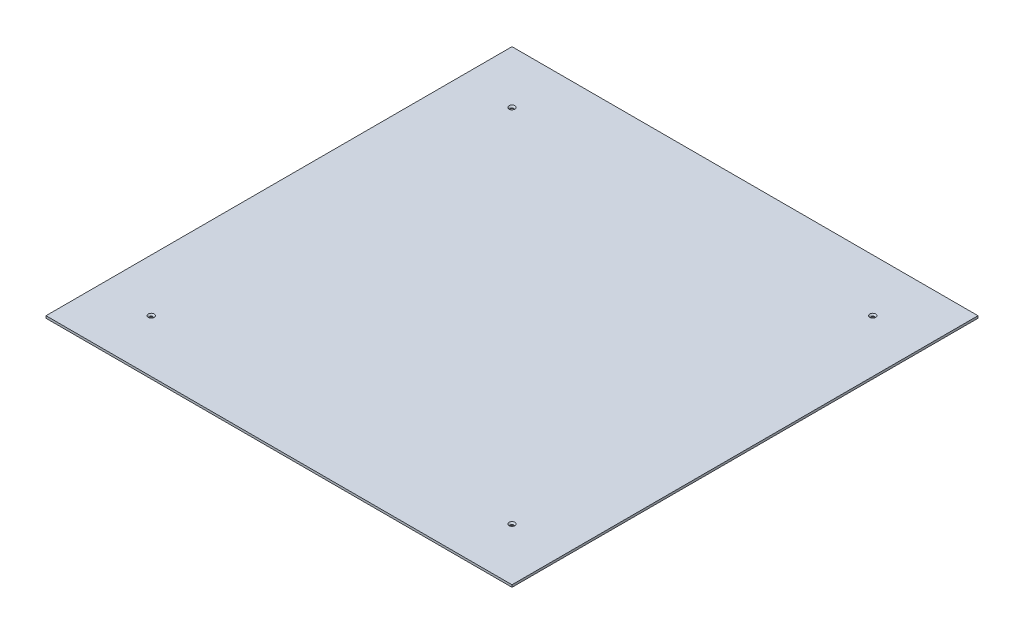
from build123d import *

# Parameters (mm, degrees)
SKETCH_1_W               = 310
SKETCH_1_H               = 310
EXTRUDE_1_DEPTH          = 1.5
HOLE_WIZARD_1_AT_2_COUNT = 2
HOLE_WIZARD_1_AT_2_PITCH = 240
HOLE_WIZARD_1_AT_3_COUNT = 2
HOLE_WIZARD_1_AT_3_PITCH = 339.41125497
HOLE_WIZARD_1_AT_4_COUNT = 2
HOLE_WIZARD_1_AT_4_PITCH = 240


with BuildPart() as part:
    # 草图1 → 凸台-拉伸1 (new body)
    with BuildSketch(Plane(origin=(0, 0, 0), x_dir=(1, 0, 0), z_dir=(0, 1, 0))):
        Rectangle(SKETCH_1_W, SKETCH_1_H)
    extrude(amount=EXTRUDE_1_DEPTH)

    # 草图3 → 打孔尺寸(%根据)内六角花形沉头螺钉的类型1 (revolve, cut)
    with BuildSketch(Plane(origin=(-120, 1.5, -120), x_dir=(0, 0, 1), z_dir=(1, 0, 0))):
        Polygon((0, 0), (0, 1.5), (1.05, 1.5), (1.05, 0.95), (2, 0), align=None)
    hole_wizard_1 = revolve(axis=Axis((-120, 7.85, -120), (0, -1, 0)), mode=Mode.SUBTRACT)

    # 打孔尺寸(%根据)内六角花形沉头螺钉的类型1 at 2: 打孔尺寸(%根据)内六角花形沉头螺钉的类型1 ×2
    with Locations(*[(i * HOLE_WIZARD_1_AT_2_PITCH, 0, 0) for i in range(1, HOLE_WIZARD_1_AT_2_COUNT)]):
        add(hole_wizard_1, mode=Mode.SUBTRACT)

    # 打孔尺寸(%根据)内六角花形沉头螺钉的类型1 at 3: 打孔尺寸(%根据)内六角花形沉头螺钉的类型1 ×2
    with Locations(*[Vector(0.707106781, 0, 0.707106781) * (i * HOLE_WIZARD_1_AT_3_PITCH) for i in range(1, HOLE_WIZARD_1_AT_3_COUNT)]):
        add(hole_wizard_1, mode=Mode.SUBTRACT)

    # 打孔尺寸(%根据)内六角花形沉头螺钉的类型1 at 4: 打孔尺寸(%根据)内六角花形沉头螺钉的类型1 ×2
    with Locations(*[(0, 0, i * HOLE_WIZARD_1_AT_4_PITCH) for i in range(1, HOLE_WIZARD_1_AT_4_COUNT)]):
        add(hole_wizard_1, mode=Mode.SUBTRACT)


solid = part.part
